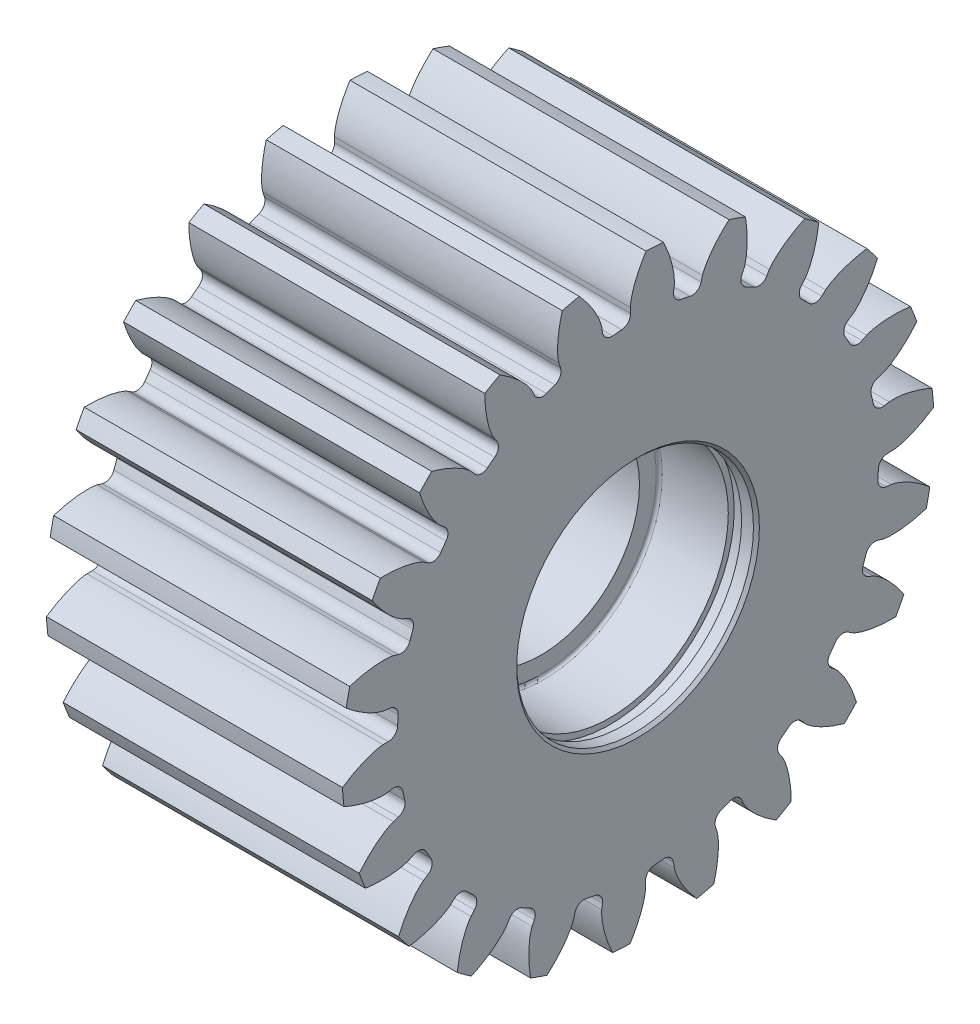
from build123d import *

# Parameters (mm, degrees)
SKETCH6_R                  = 30
BOSS_EXTRUDE1_DEPTH        = 30
CUT_EXTRUDE1_DEPTH         = 30
FILLET1_R                  = 0.95
CIRPATTERN1_COUNT          = 22
FILLET1_OF_CIRPATTERN1_R   = 0.95
BORESKETCH_R               = 10
SHAFTAXIS_DEPTH            = 30
SKETCH8_3_R                = 12
SKETCH8_3_R_2              = 10
BEARINGHOUSING_DEPTH       = 9.85
HOUSINGFILLET_R            = 0.3
RETAININGRINGSLOT_START    = 1.5
RETAININGRINGSKETCH_R      = 12.6
RETAININGRINGSLOT_DEPTH    = 1.35
HOUSINGFILLET_OF_MIRROR1_R = 0.3
CHAMFER2_SIZE              = 0.3


with BuildPart() as part:
    # Sketch6 → Boss-Extrude1 (new body)
    with BuildSketch(Plane(origin=(0, 0, 0), x_dir=(0, 0, -1), z_dir=(1, 0, 0))):
        Circle(SKETCH6_R)
    extrude(amount=BOSS_EXTRUDE1_DEPTH)

    # Sketch7 → Cut-Extrude1 (cut)
    with BuildSketch(Plane(origin=(30, 0, 0), x_dir=(0, 0, -1), z_dir=(1, 0, 0))):
        with BuildLine():
            Line((25.676763832, -2.913649631), (24.21956846, -2.748295586))
            ThreePointArc((24.21956846, -2.748295586), (24.336111092, -1.37634367), (24.375, 0))
            Line((24.375, 0), (25.841547072, 0))
            add(Edge.make_bspline(
                [(25.841547072, 0), (25.853331836, 0.000195837), (25.886371869, 0.001351454), (25.948764338, 0.005930158), (26.050356667, 0.016796089), (26.179396292, 0.035621341), (26.345551685, 0.065654458), (26.54032129, 0.108341481), (26.753160779, 0.16287569), (26.983217215, 0.230387297), (27.211247245, 0.304938707), (27.437191829, 0.38596608), (27.660798062, 0.472663702), (27.929766251, 0.584697383), (28.249557721, 0.728761629), (28.618969086, 0.911158842), (29.032465378, 1.134443883), (29.421927011, 1.364219324), (29.699997665, 1.539234474), (29.876120191, 1.6551934), (29.951471665, 1.705680237)],
                knots=[0, 0, 0, 0, 0, 0.005376749, 0.015083688, 0.02853182, 0.046610139, 0.064854849, 0.092110525, 0.119476176, 0.146842496, 0.174208854, 0.201574956, 0.228941013, 0.256307345, 0.307035032, 0.361767352, 0.416499661, 0.471231936, 0.51248349, 0.51248349, 0.51248349, 0.51248349, 0.51248349], degree=4))
            ThreePointArc((29.951471665, 1.705680237), (29.952136729, -1.69396144), (29.568164308, -5.071849709))
            add(Edge.make_bspline(
                [(25.676763832, -2.913649631), (25.688451368, -2.915172959), (25.721150419, -2.92004649), (25.78262878, -2.931630785), (25.882348146, -2.953882021), (26.008442369, -2.987136524), (26.170151992, -3.035712248), (26.358866626, -3.100087458), (26.564200142, -3.178271697), (26.785177609, -3.271291802), (27.003347849, -3.371078342), (27.218715773, -3.477064415), (27.431120933, -3.588420928), (27.685742135, -3.730066528), (27.987251069, -3.909268798), (28.333741423, -4.132154272), (28.719425463, -4.400637446), (29.080496308, -4.672859711), (29.337060734, -4.878111475), (29.498985746, -5.013188887), (29.568164308, -5.071849709)],
                knots=[0, 0, 0, 0, 0, 0.005376749, 0.015083688, 0.02853182, 0.046610139, 0.064854849, 0.092110525, 0.119476176, 0.146842496, 0.174208854, 0.201574956, 0.228941013, 0.256307345, 0.307035032, 0.361767352, 0.416499661, 0.471231936, 0.51248349, 0.51248349, 0.51248349, 0.51248349, 0.51248349], degree=4))
        make_face()
    cut_extrude1 = extrude(amount=-CUT_EXTRUDE1_DEPTH, mode=Mode.SUBTRACT)

    # Fillet1
    fillet1_edges = [part.edges().sort_by_distance(p)[0] for p in [
        (15, -2.748295586, -24.21956846),
        (15, 0, -24.375),
    ]]
    fillet(fillet1_edges, radius=FILLET1_R)

    # CirPattern1: Cut-Extrude1 ×22 about axis
    cirpattern1_axis = Axis((30, 0, 0), (-1, 0, 0))
    for i in range(1, CIRPATTERN1_COUNT):
        add(cut_extrude1.rotate(cirpattern1_axis, i * 360 / CIRPATTERN1_COUNT), mode=Mode.SUBTRACT)

    # Fillet1 of CirPattern1
    fillet1_of_cirpattern1_edges = [part.edges().sort_by_distance(p)[0] for p in [
        (15, -9.460411252, -22.464221418),
        (15, -6.867231073, -23.387641232),
        (15, -15.406100662, -18.888956758),
        (15, -13.178119925, -20.505554863),
        (15, -20.103679419, -13.783421158),
        (15, -18.421395875, -15.96223039),
        (15, -23.172577631, -7.561234749),
        (15, -22.172279887, -10.125740942),
        (15, -24.364171416, -0.726482068),
        (15, -24.126897646, -3.468924183),
        (15, -23.581924933, 6.167125868),
        (15, -24.126897646, 3.468924183),
        (15, -20.889211138, 12.561109945),
        (15, -22.172279887, 10.125740942),
        (15, -16.50417769, 17.937467597),
        (15, -18.421395875, 15.96223039),
        (15, -10.782073919, 21.860638303),
        (15, -13.178119925, 20.505554863),
        (15, -4.186470643, 24.012790103),
        (15, -6.867231073, 23.387641232),
        (15, 2.748295586, 24.21956846),
        (15, 0, 24.375),
        (15, 9.460411252, 22.464221418),
        (15, 6.867231073, 23.387641232),
        (15, 15.406100662, 18.888956758),
        (15, 13.178119925, 20.505554863),
        (15, 20.103679419, 13.783421158),
        (15, 18.421395875, 15.96223039),
        (15, 23.172577631, 7.561234749),
        (15, 22.172279887, 10.125740942),
        (15, 24.364171416, 0.726482068),
        (15, 24.126897646, 3.468924183),
        (15, 23.581924933, -6.167125868),
        (15, 24.126897646, -3.468924183),
        (15, 20.889211138, -12.561109945),
        (15, 22.172279887, -10.125740942),
        (15, 16.50417769, -17.937467597),
        (15, 18.421395875, -15.96223039),
        (15, 10.782073919, -21.860638303),
        (15, 13.178119925, -20.505554863),
        (15, 4.186470643, -24.012790103),
        (15, 6.867231073, -23.387641232),
    ]]
    fillet(fillet1_of_cirpattern1_edges, radius=FILLET1_OF_CIRPATTERN1_R)

    # boreSketch → shaftAxis (cut)
    with BuildSketch(Plane(origin=(0, 0, 0), x_dir=(0, 0, -1), z_dir=(1, 0, 0))):
        Circle(BORESKETCH_R)
    extrude(amount=SHAFTAXIS_DEPTH, mode=Mode.SUBTRACT)

    # Sketch8_3 → bearingHousing (cut)
    with BuildSketch(Plane(origin=(0, 0, 0), x_dir=(0, 0, -1), z_dir=(1, 0, 0))):
        Circle(SKETCH8_3_R)
        Circle(SKETCH8_3_R_2, mode=Mode.SUBTRACT)
    bearinghousing = extrude(amount=BEARINGHOUSING_DEPTH, mode=Mode.SUBTRACT)

    # housingFillet
    housingfillet_edges = [part.edges().sort_by_distance(p)[0] for p in [
        (9.85, 0, 12),
    ]]
    fillet(housingfillet_edges, radius=HOUSINGFILLET_R)

    # retainingRingSketch → retainingRingSlot (cut)
    with BuildSketch(Plane(origin=(0, 0, 0), x_dir=(0, 0, -1), z_dir=(1, 0, 0)).offset(RETAININGRINGSLOT_START)):
        Circle(RETAININGRINGSKETCH_R)
    retainingringslot = extrude(amount=RETAININGRINGSLOT_DEPTH, mode=Mode.SUBTRACT)

    # Mirror1: bearingHousing, retainingRingSlot across plane
    add(bearinghousing.mirror(Plane.ZY.offset(-15)), mode=Mode.SUBTRACT)
    add(retainingringslot.mirror(Plane.ZY.offset(-15)), mode=Mode.SUBTRACT)

    # housingFillet of Mirror1
    housingfillet_of_mirror1_edges = [part.edges().sort_by_distance(p)[0] for p in [
        (20.15, 0, 12),
    ]]
    fillet(housingfillet_of_mirror1_edges, radius=HOUSINGFILLET_OF_MIRROR1_R)

    # Chamfer2
    chamfer2_edges = [part.edges().sort_by_distance(p)[0] for p in [
        (0, 0, 12),
        (30, 0, 12),
    ]]
    chamfer(chamfer2_edges, length=CHAMFER2_SIZE)


solid = part.part
